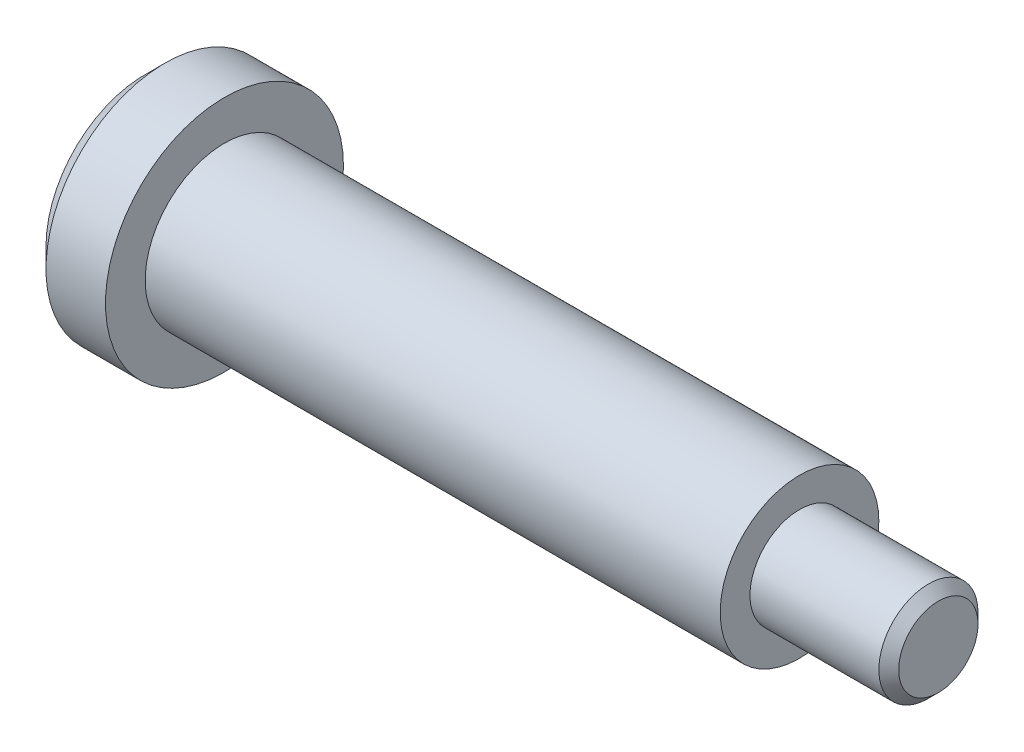
from build123d import *

# Parameters (mm, degrees)
SKETCH1_R           = 6
BOSS_EXTRUDE1_DEPTH = 4
SKETCH2_R           = 4
BOSS_EXTRUDE2_DEPTH = 29
SKETCH3_R           = 2.5
BOSS_EXTRUDE3_DEPTH = 7
CHAMFER1_SIZE       = 0.5
CHAMFER2_SIZE       = 1
SKETCH4_R           = 2.5
CUT_EXTRUDE1_DEPTH  = 1
FILLET1_R           = 0.5


with BuildPart() as part:
    # Sketch1 → Boss-Extrude1 (new body)
    with BuildSketch(Plane(origin=(0, 0, 0), x_dir=(0, 0, -1), z_dir=(1, 0, 0))):
        Circle(SKETCH1_R)
    extrude(amount=BOSS_EXTRUDE1_DEPTH)

    # Sketch2 → Boss-Extrude2 (add)
    with BuildSketch(Plane(origin=(4, 0, 0), x_dir=(0, 0, -1), z_dir=(1, 0, 0))):
        Circle(SKETCH2_R)
    extrude(amount=BOSS_EXTRUDE2_DEPTH)

    # Sketch3 → Boss-Extrude3 (add)
    with BuildSketch(Plane(origin=(33, 0, 0), x_dir=(0, 0, -1), z_dir=(1, 0, 0))):
        Circle(SKETCH3_R)
    extrude(amount=BOSS_EXTRUDE3_DEPTH)

    # Chamfer1
    chamfer1_edges = [part.edges().sort_by_distance(p)[0] for p in [
        (40, 0, 2.5),
    ]]
    chamfer(chamfer1_edges, length=CHAMFER1_SIZE)

    # Chamfer2
    chamfer2_edges = [part.edges().sort_by_distance(p)[0] for p in [
        (0, 0, 6),
    ]]
    chamfer(chamfer2_edges, length=CHAMFER2_SIZE)

    # Sketch4 → Cut-Extrude1 (cut)
    with BuildSketch(Plane.ZY):
        Circle(SKETCH4_R)
    extrude(amount=-CUT_EXTRUDE1_DEPTH, mode=Mode.SUBTRACT)

    # Fillet1
    fillet1_edges = [part.edges().sort_by_distance(p)[0] for p in [
        (0, 0, -2.5),
    ]]
    fillet(fillet1_edges, radius=FILLET1_R)


solid = part.part
